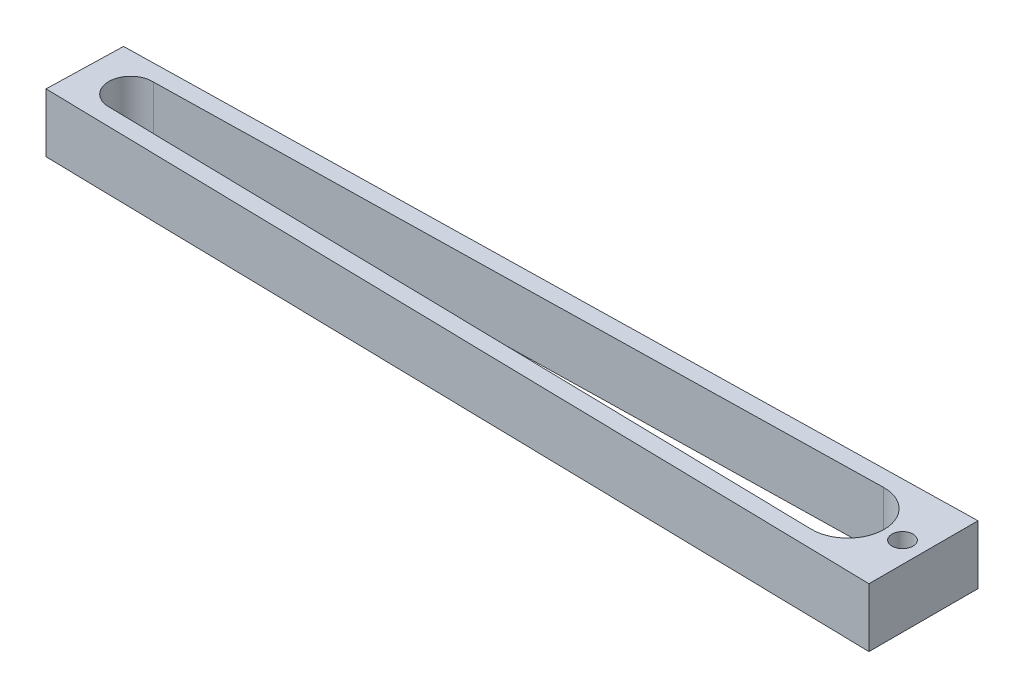
from build123d import *

# Parameters (mm, degrees)
SKETCH1_R           = 2.5
BOSS_EXTRUDE1_DEPTH = 14


with BuildPart() as part:
    # Sketch1 → Boss-Extrude1 (new body)
    with BuildSketch(Plane(origin=(0, 0, 0), x_dir=(1, 0, 0), z_dir=(0, 1, 0))):
        Polygon((-49.807795153, -41.213348306), (-90.005103209, -41.999399148), (-90.480022259, -59.993132832), (109.519977741, -64.056767627), (109.519977741, -38.097723503), align=None)
        with BuildLine():
            Line((-79.112188034, -45.787154937), (91.351489969, -42.453769592))
            ThreePointArc((91.351489969, -42.453769592), (100.137803397, -51.073442227), (91.344504386, -59.685988453))
            Line((91.344504386, -59.685988453), (-79.419326147, -56.217040409))
            ThreePointArc((-79.419326147, -56.217040409), (-84.528615041, -51.150292406), (-79.718159034, -45.799004587))
            ThreePointArc((-79.718159034, -45.799004587), (-79.415345745, -45.784273175), (-79.112188034, -45.787154937))
        make_face(mode=Mode.SUBTRACT)
        with Locations((104.519977741, -51.075218669)):
            Circle(SKETCH1_R, mode=Mode.SUBTRACT)
    extrude(amount=BOSS_EXTRUDE1_DEPTH)


solid = part.part
